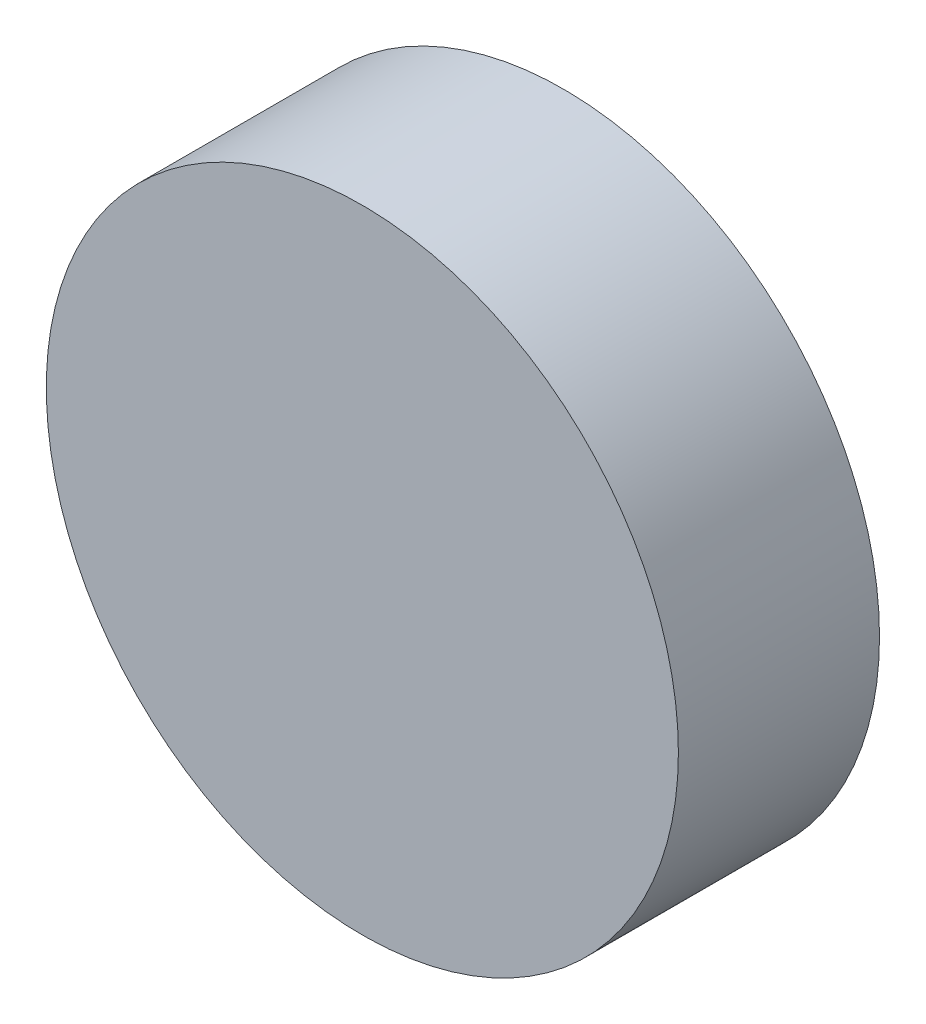
from build123d import *

# Parameters (mm, degrees)
SKETCH1_R           = 11
BOSS_EXTRUDE1_DEPTH = 7
SKETCH2_R           = 9
CUT_EXTRUDE1_DEPTH  = 5


with BuildPart() as part:
    # Sketch1 → Boss-Extrude1 (new body)
    with BuildSketch(Plane.XY):
        Circle(SKETCH1_R)
    extrude(amount=BOSS_EXTRUDE1_DEPTH)

    # Sketch2 → Cut-Extrude1 (cut)
    with BuildSketch(Plane(origin=(0, 0, 0), x_dir=(-1, 0, 0), z_dir=(0, 0, -1))):
        Circle(SKETCH2_R)
    extrude(amount=-CUT_EXTRUDE1_DEPTH, mode=Mode.SUBTRACT)


solid = part.part
